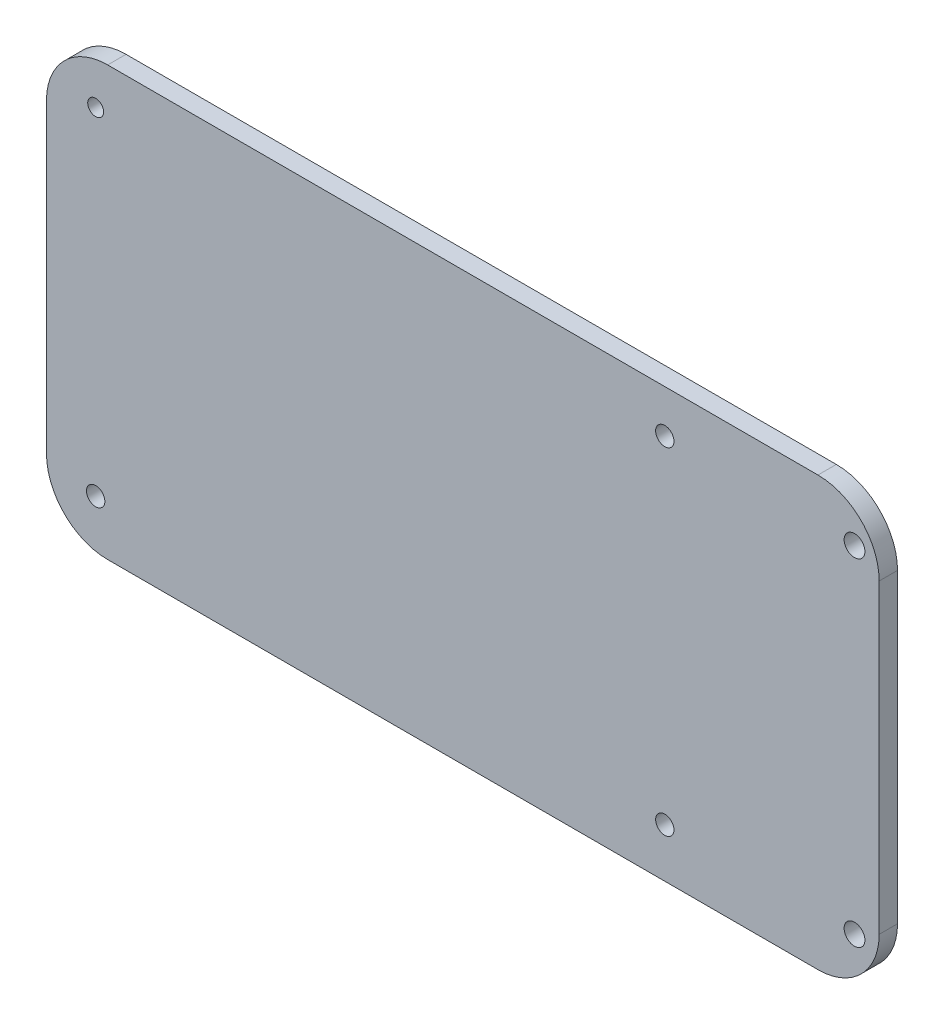
from build123d import *

# Parameters (mm, degrees)
SKETCH1_R            = 1.3
SKETCH1_R_2          = 1.5
BOSS_EXTRUDE1_DEPTH  = 3
M3_CLEARANCE_HOLE1_D = 3.4


with BuildPart() as part:
    # Sketch1 → Boss-Extrude1 (new body)
    with BuildSketch(Plane.XY):
        with BuildLine():
            Line((-66.968320128, 11.978952762), (-66.968320128, -38.021047238))
            ThreePointArc((-66.968320128, -38.021047238), (-64.039387939, -45.09211505), (-56.968320128, -48.021047238))
            Line((-56.968320128, -48.021047238), (59.094938721, -48.021047238))
            ThreePointArc((59.094938721, -48.021047238), (66.166006532, -45.09211505), (69.094938721, -38.021047238))
            Line((69.094938721, -38.021047238), (69.094938721, 11.978952762))
            ThreePointArc((69.094938721, 11.978952762), (66.166006532, 19.050020574), (59.094938721, 21.978952762))
            Line((59.094938721, 21.978952762), (-56.968320128, 21.978952762))
            ThreePointArc((-56.968320128, 21.978952762), (-64.039387939, 19.050020574), (-66.968320128, 11.978952762))
        make_face()
        with Locations((-58.93171984, 14.978952762)):
            Circle(SKETCH1_R, mode=Mode.SUBTRACT)
        with Locations((34.06828016, 14.978952762)):
            Circle(SKETCH1_R_2, mode=Mode.SUBTRACT)
        with Locations((34.06828016, -40.021047238)):
            Circle(SKETCH1_R_2, mode=Mode.SUBTRACT)
        with Locations((-58.93171984, -40.021047238)):
            Circle(SKETCH1_R_2, mode=Mode.SUBTRACT)
    extrude(amount=BOSS_EXTRUDE1_DEPTH)

    # M3 Clearance Hole1 (through all)
    with Locations(Plane(origin=(0, 0, 0), x_dir=(-1, 0, 0), z_dir=(0, 0, -1))):
        with Locations((-65.065816686, -40.021047238), (-65.065816686, 14.978952762)):
            Hole(M3_CLEARANCE_HOLE1_D / 2)


solid = part.part
